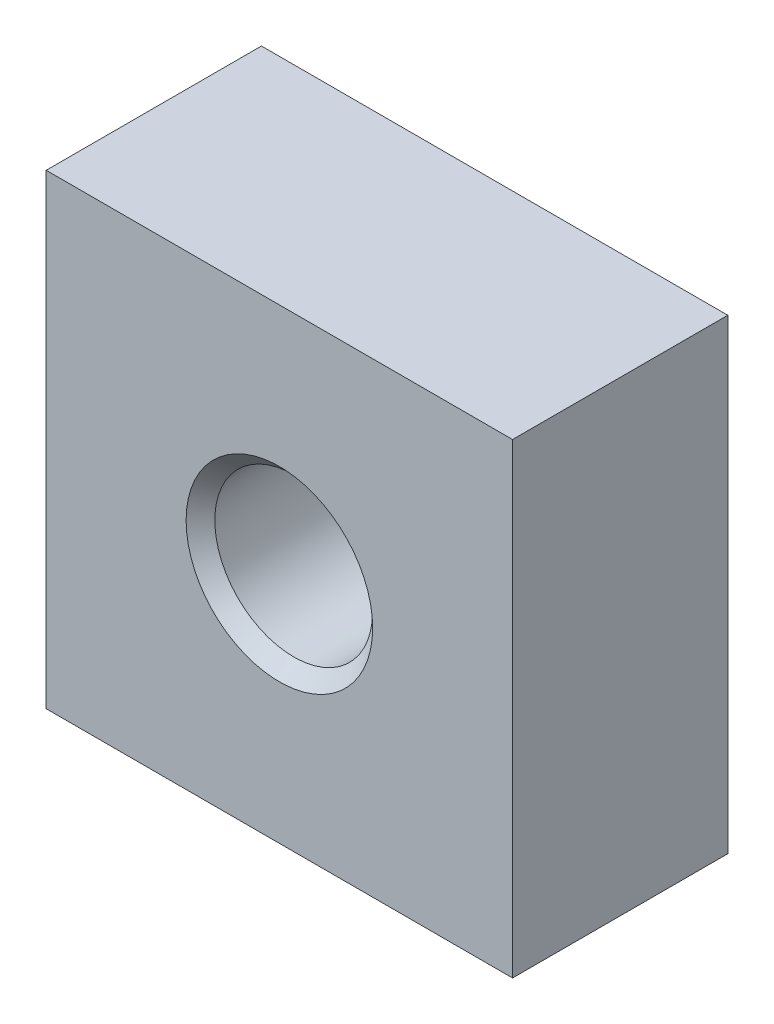
from build123d import *

# Parameters (mm, degrees)
SKETCH_1_W      = 65
SKETCH_1_H      = 65
SKETCH_1_R      = 11
EXTRUDE_1_DEPTH = 30
CHAMFER_1_SIZE  = 2


with BuildPart() as part:
    # Эскиз1 → Бобышка-Вытянуть1 (new body)
    with BuildSketch(Plane.XY):
        Rectangle(SKETCH_1_W, SKETCH_1_H)
        Circle(SKETCH_1_R, mode=Mode.SUBTRACT)
    extrude(amount=EXTRUDE_1_DEPTH)

    # Фаска1
    chamfer_1_edges = [part.edges().sort_by_distance(p)[0] for p in [
        (-11, 0, 0),
        (-11, 0, 30),
    ]]
    chamfer(chamfer_1_edges, length=CHAMFER_1_SIZE)


solid = part.part
